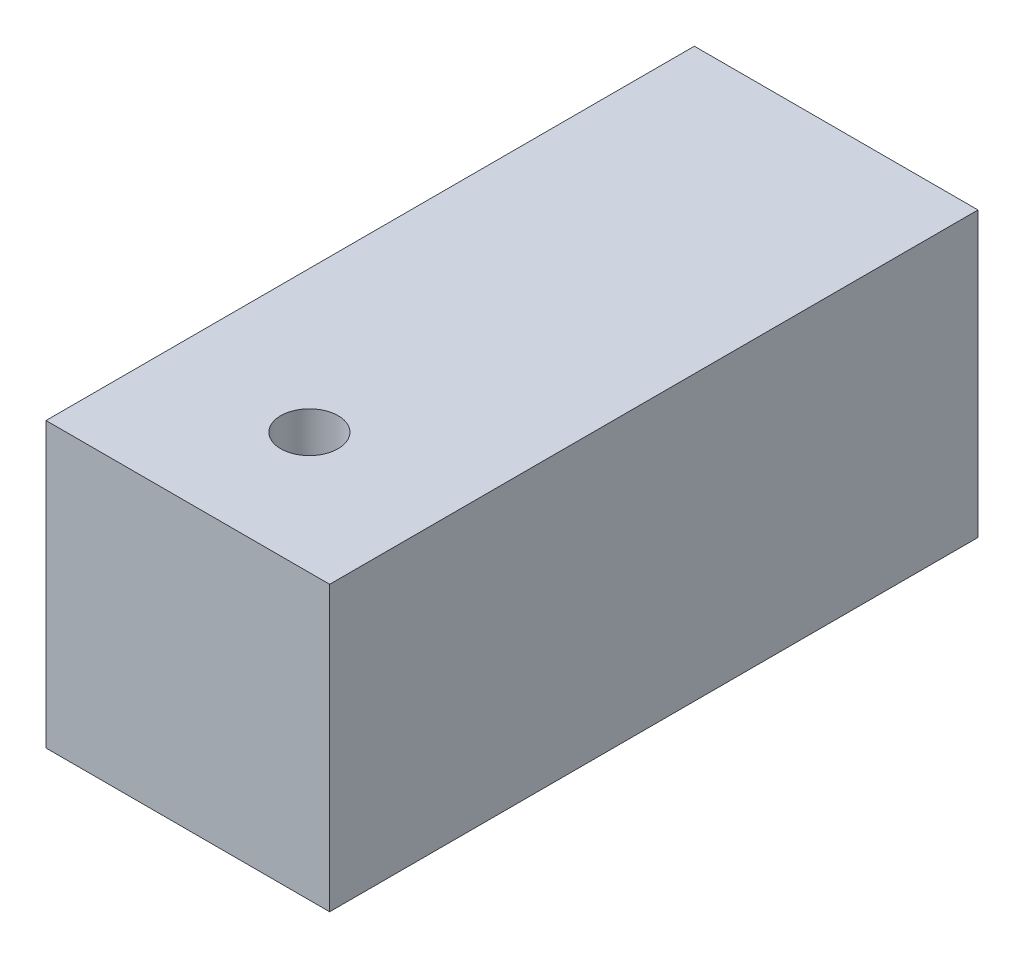
from build123d import *

# Parameters (mm, degrees)
SKETCH1_W             = 22.225
SKETCH1_H             = 22.225
BOSS_EXTRUDE1_DEPTH   = 50.8
CUT_EXTRUDE1_DEPTH    = 12.7
F_8_CLEARANCE_HOLE1_D = 4.4958
FILLET1_R             = 0.381


with BuildPart() as part:
    # Sketch1 → Boss-Extrude1 (new body)
    with BuildSketch(Plane.XY):
        Rectangle(SKETCH1_W, SKETCH1_H)
    extrude(amount=BOSS_EXTRUDE1_DEPTH)

    # Sketch2 → Cut-Extrude1 (cut)
    with BuildSketch(Plane.XZ.offset(11.1125)):
        with BuildLine():
            Line((-0.79375, 47.625), (0.79375, 47.625))
            ThreePointArc((0.79375, 47.625), (3.03881403, 46.69506403), (3.96875, 44.45))
            Line((3.96875, 44.45), (3.96875, 38.1))
            ThreePointArc((3.96875, 38.1), (3.03881403, 35.85493597), (0.79375, 34.925))
            Line((0.79375, 34.925), (-0.79375, 34.925))
            ThreePointArc((-0.79375, 34.925), (-3.03881403, 35.85493597), (-3.96875, 38.1))
            Line((-3.96875, 38.1), (-3.96875, 44.45))
            ThreePointArc((-3.96875, 44.45), (-3.03881403, 46.69506403), (-0.79375, 47.625))
        make_face()
    extrude(amount=-CUT_EXTRUDE1_DEPTH, mode=Mode.SUBTRACT)

    # #8 Clearance Hole1 (through all)
    with Locations(Plane(origin=(0, 1.5875, 0), x_dir=(-1, 0, 0), z_dir=(0, -1, 0))):
        with Locations((0, -41.275)):
            Hole(F_8_CLEARANCE_HOLE1_D / 2)

    # Fillet1
    fillet1_edges = [part.edges().sort_by_distance(p)[0] for p in [
        (0, -11.1125, 47.625),
        (3.96875, -11.1125, 41.275),
        (-3.03881403, -11.1125, 46.69506403),
        (-3.96875, -11.1125, 41.275),
        (-3.03881403, -11.1125, 35.85493597),
        (0, -11.1125, 34.925),
        (3.03881403, -11.1125, 35.85493597),
        (3.03881403, -11.1125, 46.69506403),
    ]]
    fillet(fillet1_edges, radius=FILLET1_R)


solid = part.part
